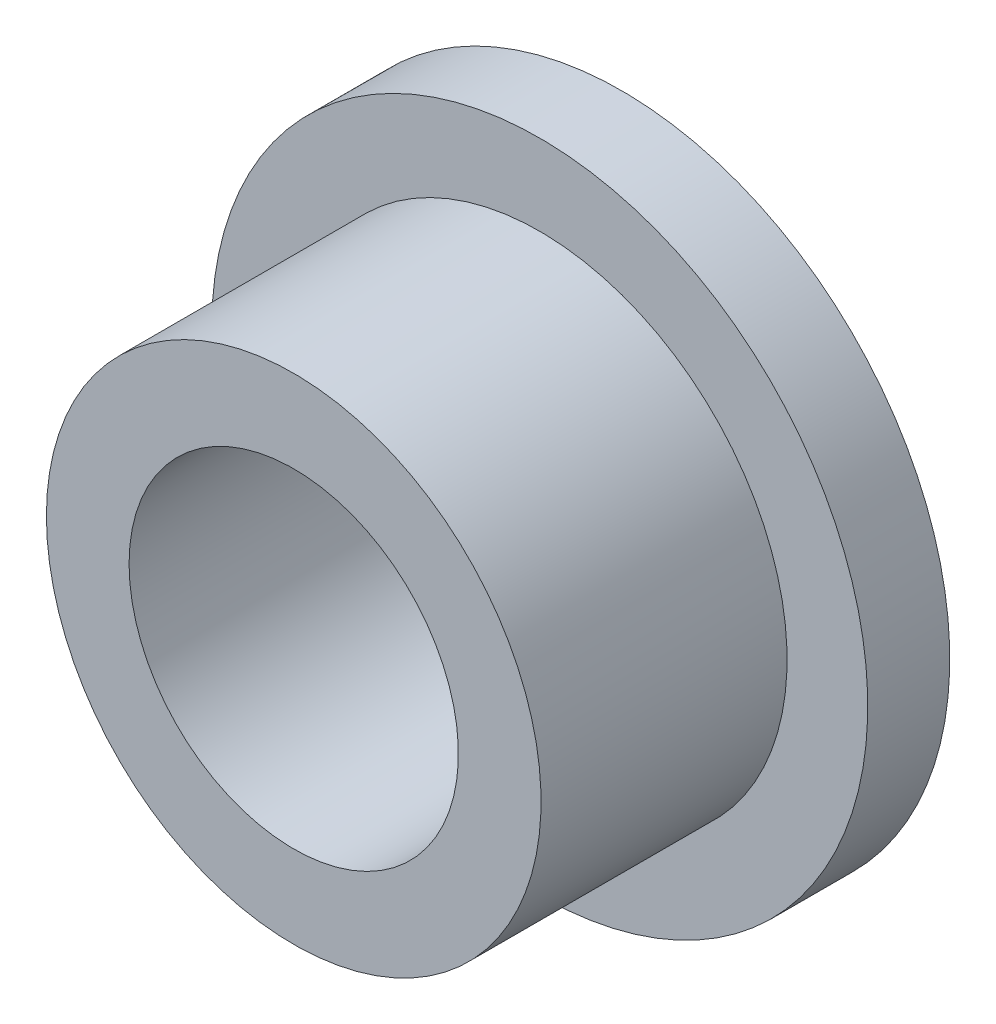
from build123d import *


with BuildPart() as part:
    # 草图1 → 旋转1 (revolve)
    with BuildSketch(Plane.XZ):
        Polygon((3.1877, 6.35), (3.1877, 0), (6.35, 0), (6.35, 1.5875), (4.7879, 1.5875), (4.7879, 6.35), align=None)
    revolve(axis=Axis((0, 0, 6.35), (0, 0, -1)))


solid = part.part
